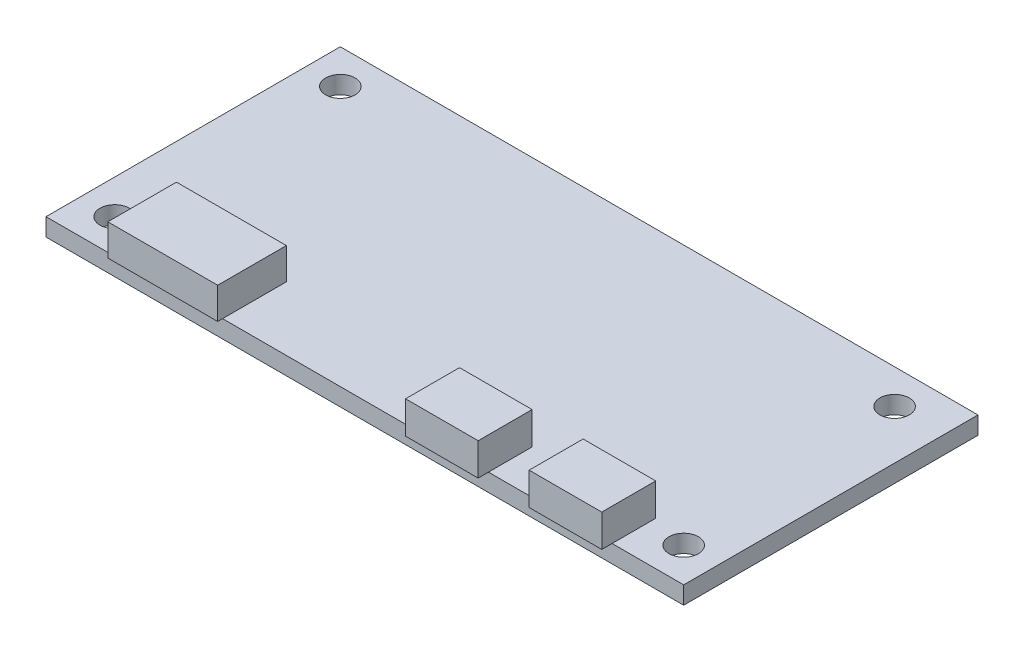
from build123d import *

# Parameters (mm, degrees)
SKETCH4_W           = 65
SKETCH4_H           = 30
SKETCH4_R           = 1.5
BOSS_EXTRUDE1_DEPTH = 1.8
SKETCH5_W           = 11.2
SKETCH5_H           = 7
BOSS_EXTRUDE2_DEPTH = 3.2
SKETCH6_W           = 7.4
SKETCH6_H           = 5.5
BOSS_EXTRUDE3_DEPTH = 3.3


with BuildPart() as part:
    # Sketch4 → Boss-Extrude1 (new body)
    with BuildSketch(Plane(origin=(0, 0, 0), x_dir=(1, 0, 0), z_dir=(0, 1, 0))):
        with Locations((5.223214286, 1.996173469)):
            Rectangle(SKETCH4_W, SKETCH4_H)
        with Locations((-23.776785714, 13.496173469)):
            Circle(SKETCH4_R, mode=Mode.SUBTRACT)
        with Locations((32.719505344, 13.496173469)):
            Circle(SKETCH4_R, mode=Mode.SUBTRACT)
        with Locations((34.223214286, -9.503826531)):
            Circle(SKETCH4_R, mode=Mode.SUBTRACT)
        with Locations((-23.776785714, -9.503826531)):
            Circle(SKETCH4_R, mode=Mode.SUBTRACT)
    extrude(amount=-BOSS_EXTRUDE1_DEPTH)

    # Sketch5 → Boss-Extrude2 (add)
    with BuildSketch(Plane(origin=(0, 0, 0), x_dir=(1, 0, 0), z_dir=(0, 1, 0))):
        with Locations((-14.876785714, -10.003826531)):
            Rectangle(SKETCH5_W, SKETCH5_H)
    extrude(amount=BOSS_EXTRUDE2_DEPTH)

    # Sketch6 → Boss-Extrude3 (add)
    with BuildSketch(Plane(origin=(0, 0, 0), x_dir=(1, 0, 0), z_dir=(0, 1, 0))):
        with Locations((14.123214286, -11.303826531)):
            Rectangle(SKETCH6_W, SKETCH6_H)
        with Locations((26.723214286, -11.303826531)):
            Rectangle(SKETCH6_W, SKETCH6_H)
    extrude(amount=BOSS_EXTRUDE3_DEPTH)


solid = part.part
